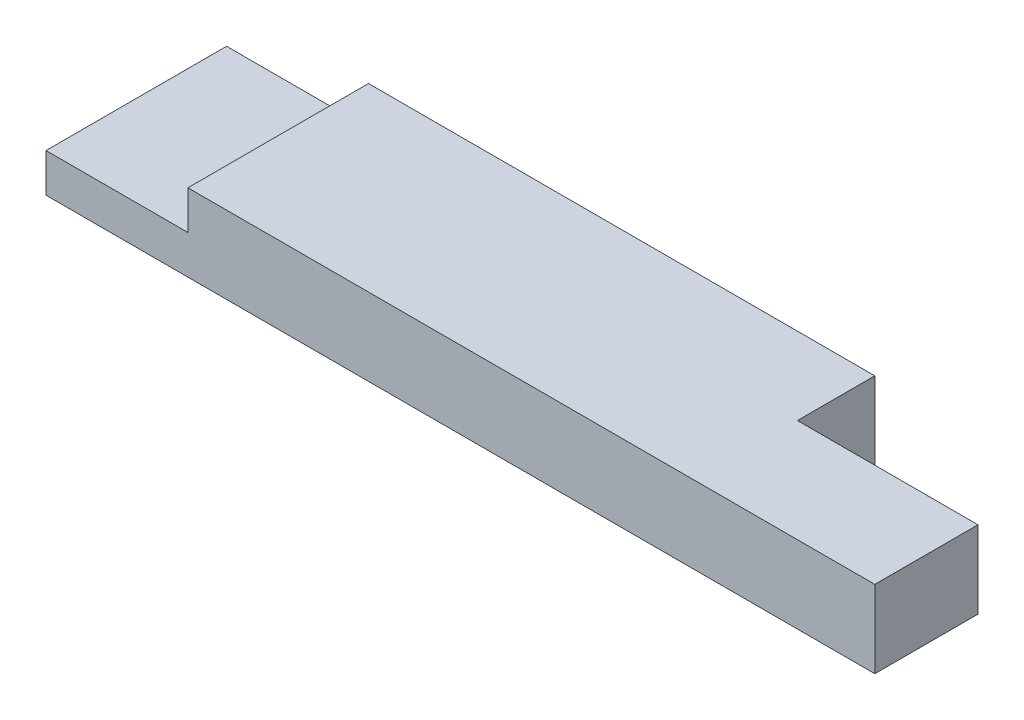
from build123d import *

# Parameters (mm, degrees)
SKETCH1_W           = 407.9875
SKETCH1_H           = 88.9
BOSS_EXTRUDE1_DEPTH = 38.1
SKETCH3_W           = 88.9
SKETCH3_H           = 38.1
CUT_EXTRUDE2_DEPTH  = 39.1
SKETCH4_W           = 69.85
SKETCH4_H           = 19.05
CUT_EXTRUDE3_DEPTH  = 89.9


with BuildPart() as part:
    # Sketch1 → Boss-Extrude1 (new body)
    with BuildSketch(Plane(origin=(0, 0, 0), x_dir=(1, 0, 0), z_dir=(0, 1, 0))):
        with Locations((203.99375, 44.45)):
            Rectangle(SKETCH1_W, SKETCH1_H)
    extrude(amount=BOSS_EXTRUDE1_DEPTH)

    # Sketch3 → Cut-Extrude2 (cut, through all)
    with BuildSketch(Plane(origin=(0, 38.1, 0), x_dir=(1, 0, 0), z_dir=(0, 1, 0))):
        with Locations((363.5375, 69.85)):
            Rectangle(SKETCH3_W, SKETCH3_H)
    extrude(amount=-CUT_EXTRUDE2_DEPTH, mode=Mode.SUBTRACT)

    # Sketch4 → Cut-Extrude3 (cut, through all)
    with BuildSketch(Plane(origin=(0, 0, -88.9), x_dir=(-1, 0, 0), z_dir=(0, 0, -1))):
        with Locations((-34.925, 28.575)):
            Rectangle(SKETCH4_W, SKETCH4_H)
    extrude(amount=-CUT_EXTRUDE3_DEPTH, mode=Mode.SUBTRACT)


solid = part.part
